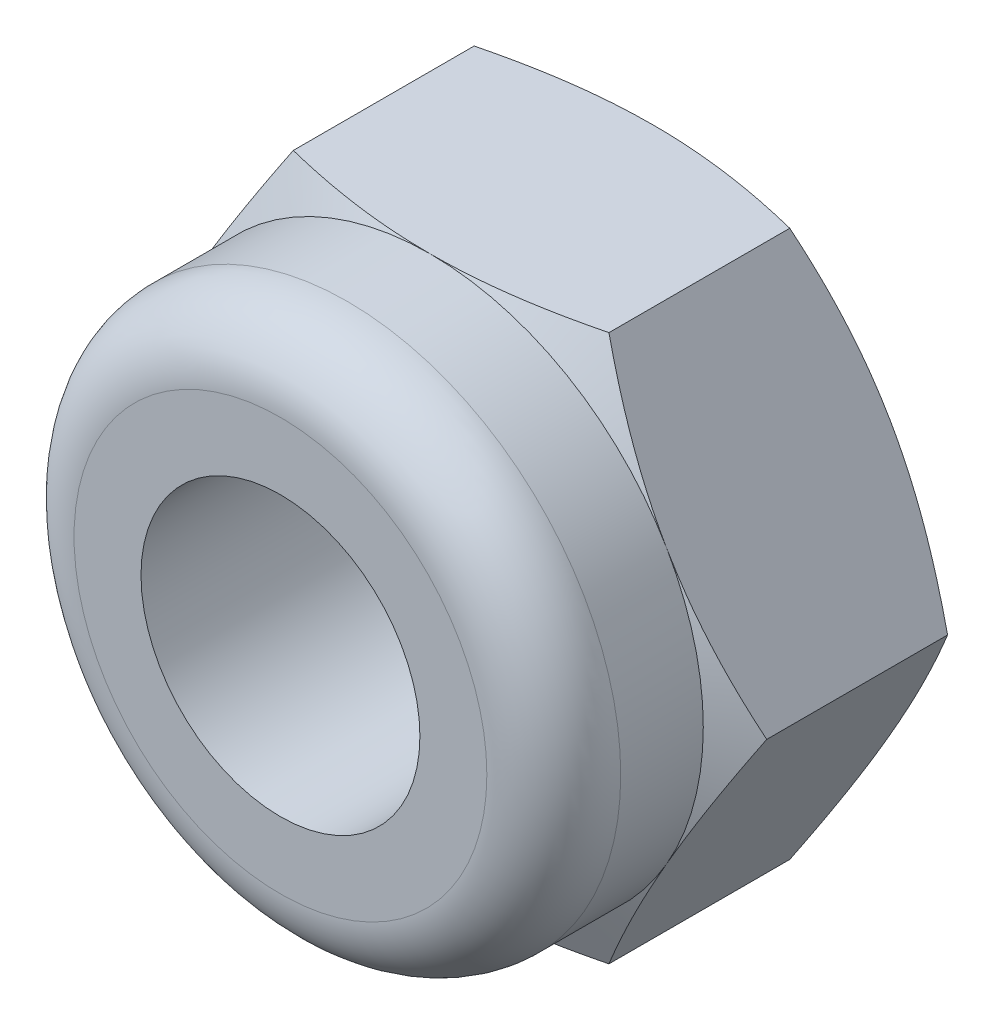
from build123d import *

# Parameters (mm, degrees)
SKETCH1_R           = 1.25
BOSS_EXTRUDE1_DEPTH = 2
SKETCH2_R           = 2.45
SKETCH2_R_2         = 1.25
BOSS_EXTRUDE2_DEPTH = 1.34
FILLET1_R           = 0.6
CHAMFER1_SIZE       = 0.3


with BuildPart() as part:
    # Sketch1 → Boss-Extrude1 (new body)
    with BuildSketch(Plane.XY):
        Polygon((-1.41450816, 2.45), (1.41450816, 2.45), (2.829016319, 0), (1.41450816, -2.45), (-1.41450816, -2.45), (-2.829016319, 0), align=None)
        Circle(SKETCH1_R, mode=Mode.SUBTRACT)
    extrude(amount=BOSS_EXTRUDE1_DEPTH)

    # Sketch2 → Boss-Extrude2 (add)
    with BuildSketch(Plane.XY.offset(2)):
        Circle(SKETCH2_R)
        Circle(SKETCH2_R_2, mode=Mode.SUBTRACT)
    extrude(amount=BOSS_EXTRUDE2_DEPTH)

    # Fillet1
    fillet1_edges = [part.edges().sort_by_distance(p)[0] for p in [
        (-2.45, 0, 3.34),
    ]]
    fillet(fillet1_edges, radius=FILLET1_R)

    # Sketch3 → Cut-Revolve1 (revolve, cut)
    with BuildSketch(Plane(origin=(0, 0, 0), x_dir=(0, 0, -1), z_dir=(1, 0, 0))):
        Polygon((-2, 2.45), (-1.750031536, 2.95), (-0.249968464, 2.95), (0, 2.45), (0, 3.373191212), (-2, 3.373191212), align=None)
    revolve(axis=Axis((0, 0, 0), (0, 0, -1)), mode=Mode.SUBTRACT)

    # Chamfer1
    chamfer1_edges = [part.edges().sort_by_distance(p)[0] for p in [
        (-1.25, 0, 0),
    ]]
    chamfer(chamfer1_edges, length=CHAMFER1_SIZE)


solid = part.part
